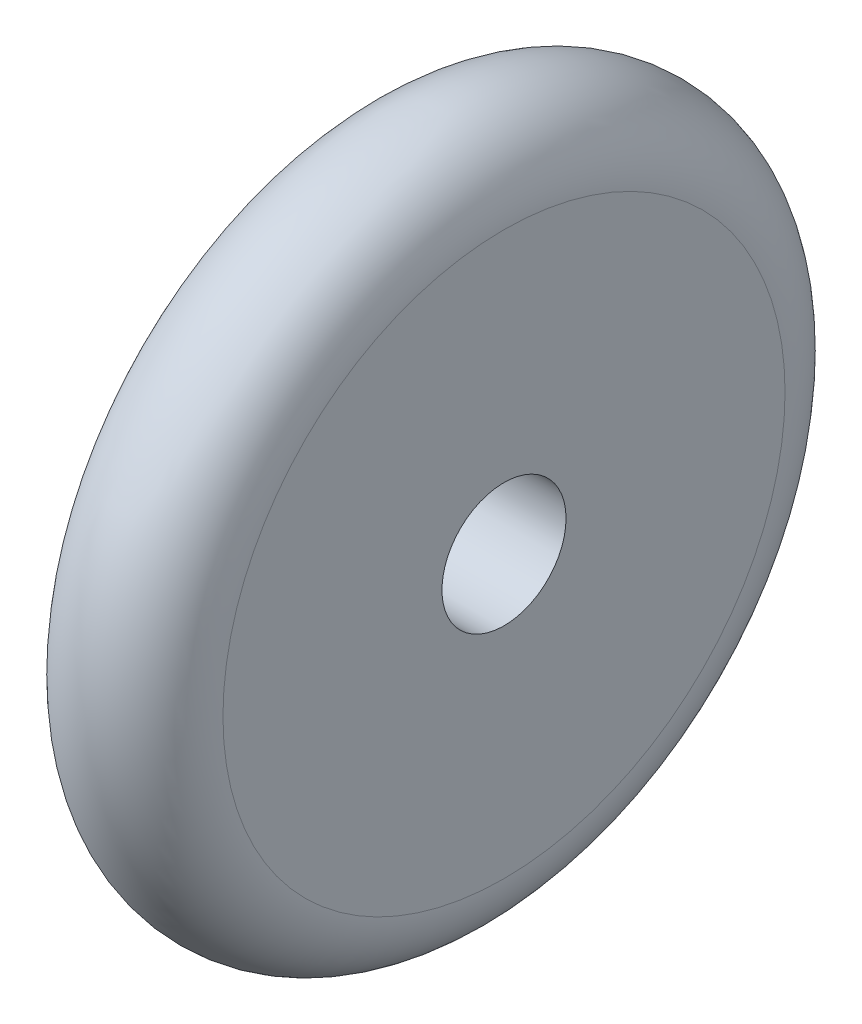
from build123d import *

# Parameters (mm, degrees)
SKETCH1_W = 4
SKETCH1_H = 6


with BuildPart() as part:
    # Sketch1 → Revolve1 (revolve)
    with BuildSketch(Plane.XY):
        with Locations((2, 3)):
            Rectangle(SKETCH1_W, SKETCH1_H)
        with BuildLine():
            ThreePointArc((0, 6), (2, 8), (4, 6))
            Line((4, 6), (0, 6))
        make_face()
    revolve(axis=Axis((4, -1.7, 0), (-1, 0, 0)))


solid = part.part
